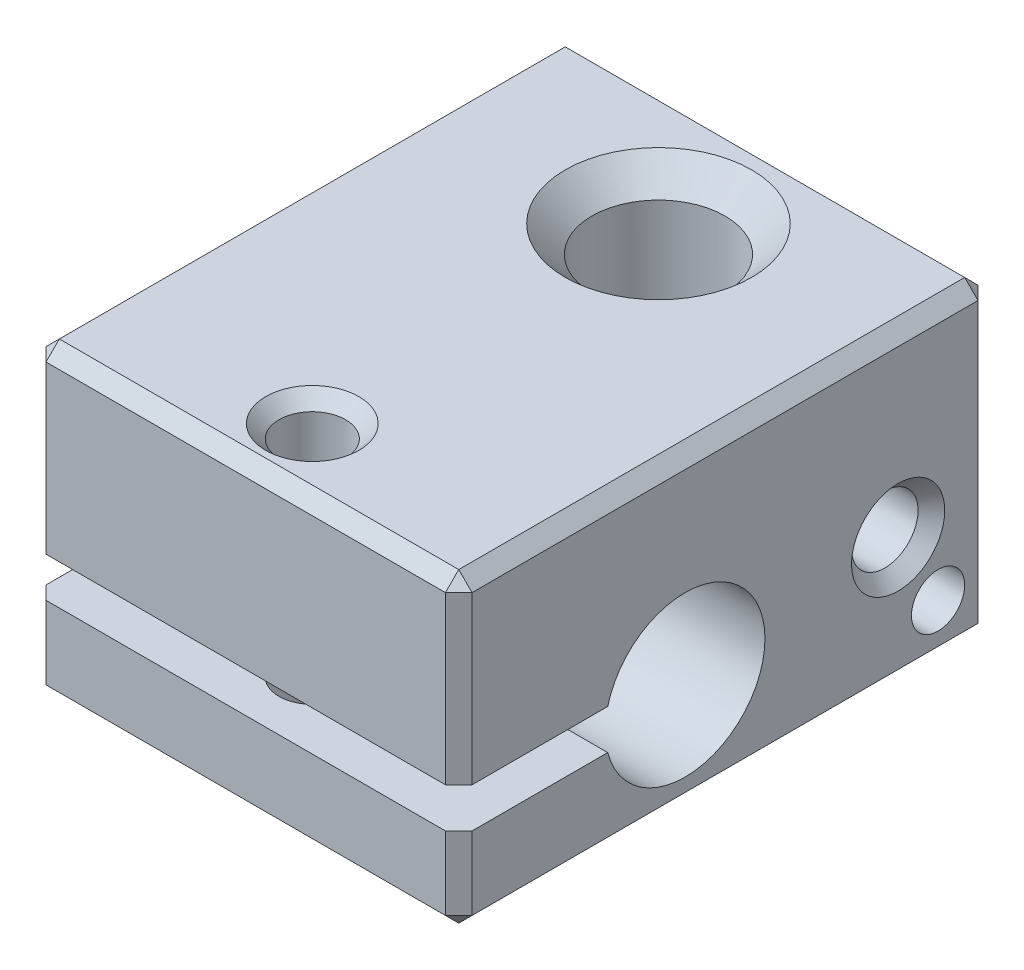
from build123d import *

# Parameters (mm, degrees)
SKETCH_1_W            = 20
SKETCH_1_H            = 11.5
EXTRUDE_1_DEPTH       = 8
CUT_EXTRUDE_1_REACH   = 18
HOLE_WIZARD_M31_D     = 2.5
HOLE_WIZARD_M31_DEPTH = 11.5
HOLE_WIZARD_M31_TIP   = 0.751075774
HOLE_WIZARD_M61_D     = 5
HOLE_WIZARD_M61_DEPTH = 11.5
CHAMFER_1_SIZE        = 0.5
CHAMFER_2_SIZE        = 1
HOLE_WIZARD_M32_D     = 2.5
HOLE_WIZARD_M32_DEPTH = 3.8
HOLE_WIZARD_M32_TIP   = 0.751075774
CHAMFER_3_SIZE        = 0.5
HOLE_WIZARD_1_D       = 1.5
HOLE_WIZARD_1_DEPTH   = 4.4
HOLE_WIZARD_1_TIP     = 0.450645464
HOLE_WIZARD_2_D       = 2
HOLE_WIZARD_2_DEPTH   = 2
HOLE_WIZARD_2_TIP     = 0.600860619
CHAMFER_4_SIZE        = 0.5


with BuildPart() as part:
    # Эскиз1 → Бобышка-Вытянуть1 (new body, symmetric)
    with BuildSketch(Plane(origin=(0, 0, 0), x_dir=(0, 0, -1), z_dir=(1, 0, 0))):
        Rectangle(SKETCH_1_W, SKETCH_1_H)
    extrude(amount=EXTRUDE_1_DEPTH, both=True)

    # Эскиз2 → Вырез-Вытянуть1 (cut, up to next)
    with BuildSketch(Plane(origin=(8, 0, 0), x_dir=(0, 0, -1), z_dir=(1, 0, 0)), mode=Mode.PRIVATE) as cut_extrude_1_sk1:
        with BuildLine():
            Line((-10, -1), (-4.40473751, -1))
            ThreePointArc((-4.40473751, -1), (1.5, -1.75), (-4.40473751, -2.5))
            Line((-4.40473751, -2.5), (-10, -2.5))
            Line((-10, -2.5), (-10, -1))
        make_face()
    cut_extrude_1_tool1 = extrude(cut_extrude_1_sk1.sketch, amount=-CUT_EXTRUDE_1_REACH, mode=Mode.PRIVATE) & part.part
    add(cut_extrude_1_tool1.solids().sort_by_distance((8, -1.75, 2.800956))[0], mode=Mode.SUBTRACT)

    # Отверстие обработанное метчиком M31
    with Locations(Plane(origin=(0, 5.75, 0), x_dir=(-1, 0, 0), z_dir=(0, 1, 0))):
        with Locations((0, 7.5)):
            Hole(HOLE_WIZARD_M31_D / 2, depth=HOLE_WIZARD_M31_DEPTH)
            with Locations((0, 0, -(HOLE_WIZARD_M31_DEPTH + HOLE_WIZARD_M31_TIP / 2))):  # 118° drill point
                Cone(0, HOLE_WIZARD_M31_D / 2, HOLE_WIZARD_M31_TIP, mode=Mode.SUBTRACT)

    # Отверстие обработанное метчиком M61
    with Locations(Plane(origin=(0, 5.75, 0), x_dir=(-1, 0, 0), z_dir=(0, 1, 0))):
        with Locations((0, -5.5)):
            Hole(HOLE_WIZARD_M61_D / 2, depth=HOLE_WIZARD_M61_DEPTH)

    # Фаска1
    chamfer_1_edges = [part.edges().sort_by_distance(p)[0] for p in [
        (-1.25, 5.75, 7.5),
        (-1.25, -5.75, 7.5),
    ]]
    chamfer(chamfer_1_edges, length=CHAMFER_1_SIZE)

    # Фаска2
    chamfer_2_edges = [part.edges().sort_by_distance(p)[0] for p in [
        (-2.5, 5.75, -5.5),
        (-2.5, -5.75, -5.5),
    ]]
    chamfer(chamfer_2_edges, length=CHAMFER_2_SIZE)

    # Отверстие обработанное метчиком M32
    with Locations(Plane(origin=(8, 0, 0), x_dir=(0, 0, -1), z_dir=(1, 0, 0))):
        with Locations((6.5, -0.95)):
            Hole(HOLE_WIZARD_M32_D / 2, depth=HOLE_WIZARD_M32_DEPTH)
            with Locations((0, 0, -(HOLE_WIZARD_M32_DEPTH + HOLE_WIZARD_M32_TIP / 2))):  # 118° drill point
                Cone(0, HOLE_WIZARD_M32_D / 2, HOLE_WIZARD_M32_TIP, mode=Mode.SUBTRACT)

    # Фаска3
    chamfer_3_edges = [part.edges().sort_by_distance(p)[0] for p in [
        (8, -0.95, -7.75),
    ]]
    chamfer(chamfer_3_edges, length=CHAMFER_3_SIZE)

    # Отверстие1
    with Locations(Plane(origin=(8, 0, 0), x_dir=(0, 0, -1), z_dir=(1, 0, 0))):
        with Locations((8, -3.75)):
            Hole(HOLE_WIZARD_1_D / 2, depth=HOLE_WIZARD_1_DEPTH)
            with Locations((0, 0, -(HOLE_WIZARD_1_DEPTH + HOLE_WIZARD_1_TIP / 2))):  # 118° drill point
                Cone(0, HOLE_WIZARD_1_D / 2, HOLE_WIZARD_1_TIP, mode=Mode.SUBTRACT)

    # Отверстие2
    with Locations(Plane(origin=(8, 0, 0), x_dir=(0, 0, -1), z_dir=(1, 0, 0))):
        with Locations((8, -3.75)):
            Hole(HOLE_WIZARD_2_D / 2, depth=HOLE_WIZARD_2_DEPTH)
            with Locations((0, 0, -(HOLE_WIZARD_2_DEPTH + HOLE_WIZARD_2_TIP / 2))):  # 118° drill point
                Cone(0, HOLE_WIZARD_2_D / 2, HOLE_WIZARD_2_TIP, mode=Mode.SUBTRACT)

    # Фаска4
    chamfer_4_edges = [part.edges().sort_by_distance(p)[0] for p in [
        (8, 0, -10),
        (8, 5.75, 0),
        (-8, -4.125, 10),
        (8, -4.125, 10),
        (8, 2.375, 10),
        (-8, 5.75, 0),
        (-8, 0, -10),
        (-8, -5.75, 0),
        (-8, 2.375, 10),
        (8, -5.75, 0),
        (0, 5.75, 10),
        (0, 5.75, -10),
        (0, -5.75, -10),
        (0, -5.75, 10),
    ]]
    chamfer(chamfer_4_edges, length=CHAMFER_4_SIZE)


solid = part.part
